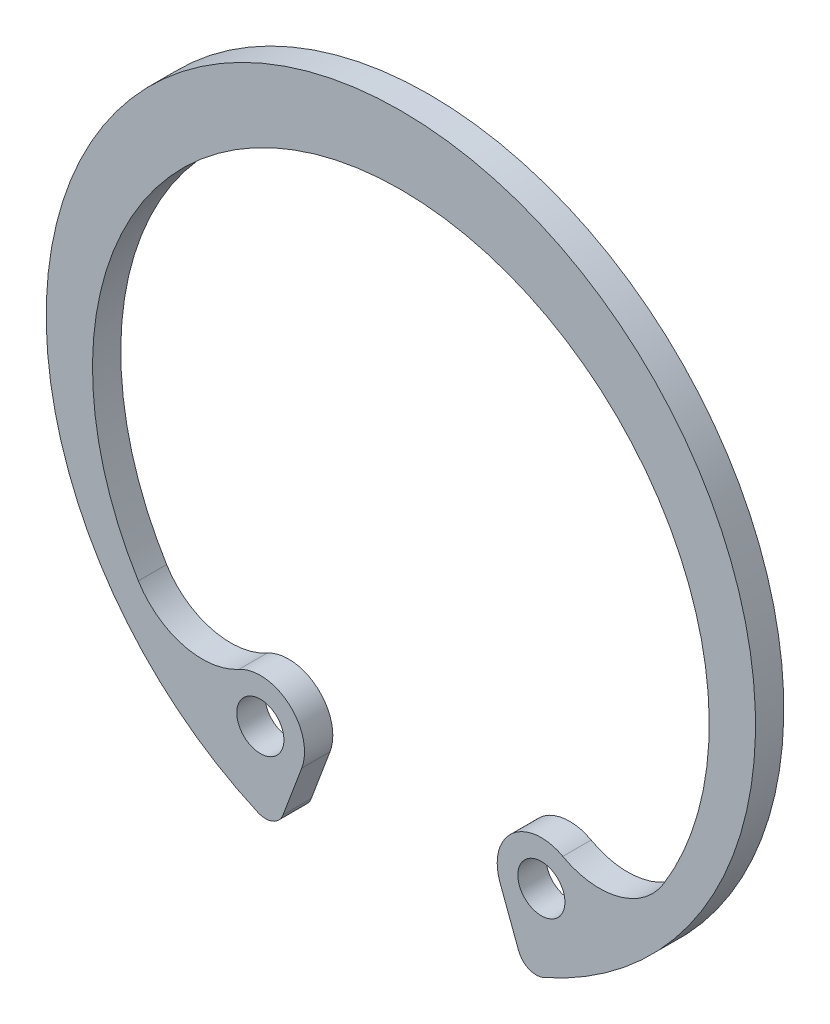
from build123d import *

# Parameters (mm, degrees)
SKETCH3_R                = 1
BOSS_EXTRUDE1_DEPTH      = 0.6
BOSS_EXTRUDE1_DEPTH_BACK = 0.6
FILLET1_R                = 0.79375


with BuildPart() as part:
    # Sketch3 → Boss-Extrude1 (new body, two sides)
    with BuildSketch(Plane.XY) as boss_extrude1_sk:
        with BuildLine():
            Line((-4.20731071, -11.215994677), (-5.285853659, -14.091211839))
            ThreePointArc((-5.285853659, -14.091211839), (0, 15.05), (5.285853659, -14.091211839))
            Line((5.285853659, -14.091211839), (4.20731071, -11.215994677))
            ThreePointArc((4.20731071, -11.215994677), (4.738417429, -9.137470587), (6.87245355, -8.917865085))
            ThreePointArc((6.87245355, -8.917865085), (9.230393871, -9.214719738), (11.140467802, -7.800639534))
            ThreePointArc((11.140467802, -7.800639534), (0, 12.15), (-11.140467802, -7.800639534))
            ThreePointArc((-11.140467802, -7.800639534), (-9.230393871, -9.214719738), (-6.87245355, -8.917865085))
            ThreePointArc((-6.87245355, -8.917865085), (-4.738417429, -9.137470587), (-4.20731071, -11.215994677))
        make_face()
        with Locations((-5.962860358, -10.557458091)):
            Circle(SKETCH3_R, mode=Mode.SUBTRACT)
        with Locations((5.962860358, -10.557458091)):
            Circle(SKETCH3_R, mode=Mode.SUBTRACT)
    extrude(amount=BOSS_EXTRUDE1_DEPTH)
    extrude(boss_extrude1_sk.sketch, amount=-BOSS_EXTRUDE1_DEPTH_BACK)

    # Fillet1
    fillet1_edges = [part.edges().sort_by_distance(p)[0] for p in [
        (5.285853659, -14.091211839, 0),
        (-5.285853659, -14.091211839, 0),
    ]]
    fillet(fillet1_edges, radius=FILLET1_R)


solid = part.part
